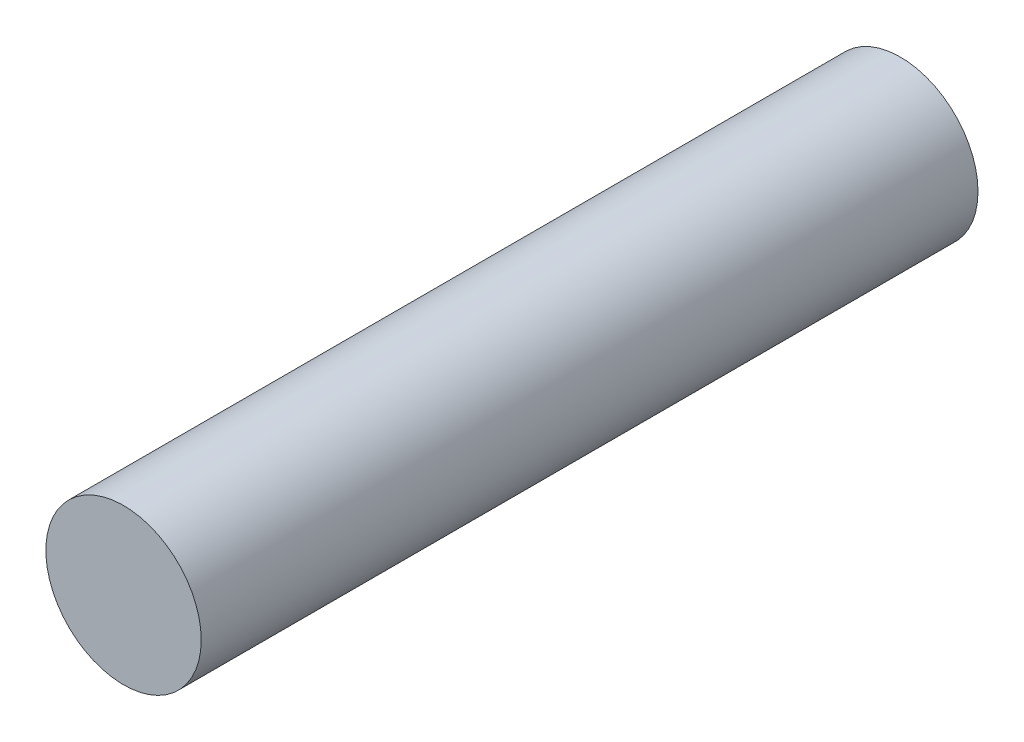
from build123d import *

# Parameters (mm, degrees)
SKETCH1_R           = 1.5
BOSS_EXTRUDE1_DEPTH = 15


with BuildPart() as part:
    # Sketch1 → Boss-Extrude1 (new body)
    with BuildSketch(Plane.XY):
        with Locations((0.884706706, 2.567544382)):
            Circle(SKETCH1_R)
    extrude(amount=BOSS_EXTRUDE1_DEPTH)


solid = part.part
